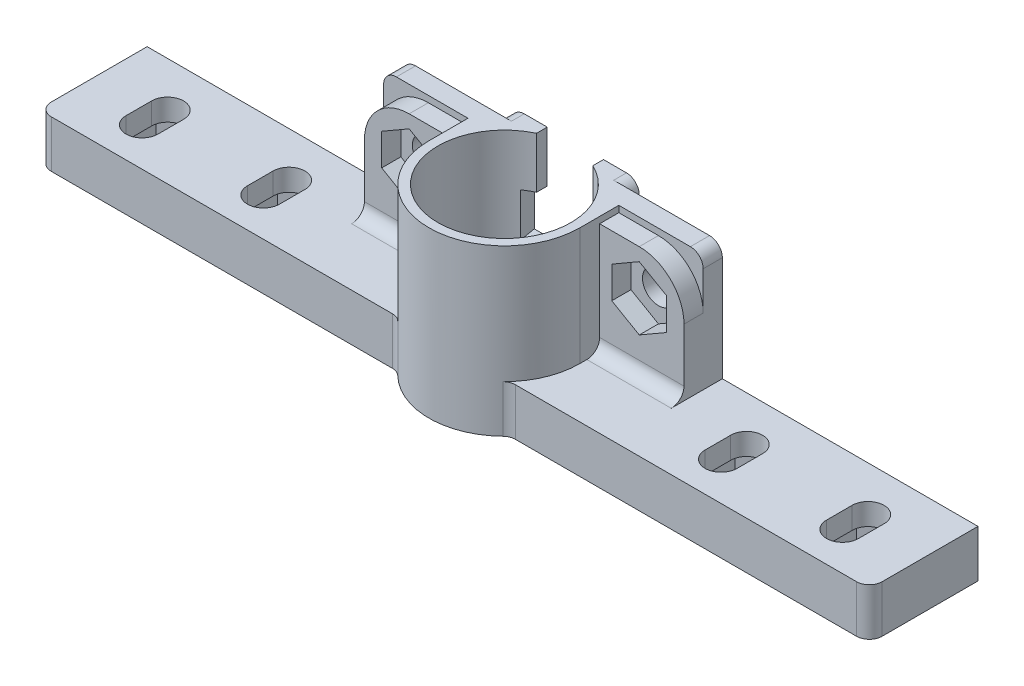
from build123d import *

# Parameters (mm, degrees)
SKETCH1_R                         = 5.2
BASE_SHAPE_DEPTH                  = 11.4
BOTTOM_EXTRUDE_DEPTH              = 1.5
PIN_CUT_REACH                     = 19.917
SKETCH3_R                         = 3
M2_SCREW_HOLES_REACH              = 21.885
SKETCH5_R                         = 1.25
EXTRA_THREAD_EXTRUDES_DEPTH       = 1.5
SKETCH7_R                         = 4.05
INNER_BEARING_FREE_CUT_DEPTH      = 0.5
BUMPER_CUT_DEPTH                  = 1.7
MILLED_HOLE_FILLETS_R             = 1
BUMPER_BODY_TOP_CUT_REACH         = 22.428
BUMPER_BODY_TOP_CUT_END_RADIUS    = 5.2
SKETCH9_W                         = 4.4
SKETCH9_H                         = 4
BUMPER_SWITCH_MOUNT_EXTRUDE_DEPTH = 3.7
BUMPER_SWITCH_MOUNT_FILLETS_R     = 1
BUMPER_SWITCH_NUT_CUTS_DEPTH      = 2


with BuildPart() as part:
    # Sketch1 → Base shape (new body)
    with BuildSketch(Plane(origin=(0, 0, 0), x_dir=(1, 0, 0), z_dir=(0, 1, 0))):
        with BuildLine():
            ThreePointArc((-5.9, 0), (0, -5.9), (5.9, 0))
            Line((5.9, 0), (5.9, 3.05))
            Line((5.9, 3.05), (12.5, 3.05))
            Line((12.5, 3.05), (12.5, 4.55))
            Line((12.5, 4.55), (5, 4.55))
            Line((5, 4.55), (5, 5.55))
            Line((5, 5.55), (-5, 5.55))
            Line((-5, 5.55), (-5, 4.55))
            Line((-5, 4.55), (-12.5, 4.55))
            Line((-12.5, 4.55), (-12.5, 3.05))
            Line((-12.5, 3.05), (-5.9, 3.05))
            Line((-5.9, 3.05), (-5.9, 0))
        make_face()
        with Locations(Location((0, 0, 0), (0, 0, 270))):
            Circle(SKETCH1_R, mode=Mode.SUBTRACT)
    extrude(amount=BASE_SHAPE_DEPTH)

    # Sketch2 → Bottom extrude (add)
    with BuildSketch(Plane.XZ):
        with BuildLine():
            Line((-5.9, -3.05), (-12.5, -3.05))
            Line((-12.5, -3.05), (-12.5, -4.55))
            Line((-12.5, -4.55), (-5, -4.55))
            Line((-5, -4.55), (-5, -5.55))
            Line((-5, -5.55), (5, -5.55))
            Line((5, -5.55), (5, -4.55))
            Line((5, -4.55), (12.5, -4.55))
            Line((12.5, -4.55), (12.5, -3.05))
            Line((12.5, -3.05), (5.9, -3.05))
            Line((5.9, -3.05), (5.9, 0))
            ThreePointArc((5.9, 0), (0, 5.9), (-5.9, 0))
            Line((-5.9, 0), (-5.9, -3.05))
        make_face()
    extrude(amount=BOTTOM_EXTRUDE_DEPTH)

    # Sketch3 → Pin cut (cut, up to next)
    with BuildSketch(Plane(origin=(0, 0, 0), x_dir=(1, 0, 0), z_dir=(0, 1, 0)), mode=Mode.PRIVATE) as pin_cut_sk1:
        with Locations(Location((0, 0, 0), (0, 0, 270))):
            Circle(SKETCH3_R)
    pin_cut_tool1 = extrude(pin_cut_sk1.sketch, amount=-PIN_CUT_REACH, mode=Mode.PRIVATE) & part.part
    add(pin_cut_tool1.solids().sort_by_distance((0, 0, 0))[0], mode=Mode.SUBTRACT)

    # Sketch5 → M2 screw holes (cut, up to next)
    with BuildSketch(Plane(origin=(0, 0, -4.55), x_dir=(-1, 0, 0), z_dir=(0, 0, -1)), mode=Mode.PRIVATE) as m2_screw_holes_sk1:
        with Locations((-9, 7.4)):
            Circle(SKETCH5_R)
    m2_screw_holes_tool1 = extrude(m2_screw_holes_sk1.sketch, amount=-M2_SCREW_HOLES_REACH, mode=Mode.PRIVATE) & part.part
    # Sketch5 → M2 screw holes (cut, up to next)
    with BuildSketch(Plane(origin=(0, 0, -4.55), x_dir=(-1, 0, 0), z_dir=(0, 0, -1)), mode=Mode.PRIVATE) as m2_screw_holes_sk2:
        with Locations((9, 7.4)):
            Circle(SKETCH5_R)
    m2_screw_holes_tool2 = extrude(m2_screw_holes_sk2.sketch, amount=-M2_SCREW_HOLES_REACH, mode=Mode.PRIVATE) & part.part
    add(m2_screw_holes_tool1.solids().sort_by_distance((9, 7.4, -4.55))[0], mode=Mode.SUBTRACT)
    add(m2_screw_holes_tool2.solids().sort_by_distance((-9, 7.4, -4.55))[0], mode=Mode.SUBTRACT)

    # Sketch6 → Extra thread extrudes (add)
    with BuildSketch(Plane.XY.offset(-3.05)):
        with BuildLine():
            Line((-5.9, 5.775192319), (-5.9, 9.024807681))
            ThreePointArc((-5.9, 9.024807681), (-7.18848501, 10.394730946), (-9, 10.9))
            ThreePointArc((-9, 10.9), (-11.474873734, 9.874873734), (-12.5, 7.4))
            ThreePointArc((-12.5, 7.4), (-9.836660027, 4.001470906), (-5.9, 5.775192319))
        make_face()
        Polygon((-11.15, 8.641303079), (-9, 9.882606158), (-6.85, 8.641303079), (-6.85, 6.158696921), (-9, 4.917393842), (-11.15, 6.158696921), align=None, mode=Mode.SUBTRACT)
        with BuildLine():
            Line((-5.9, -1.5), (-5.9, 5.775192319))
            ThreePointArc((-5.9, 5.775192319), (-9.836660027, 4.001470906), (-12.5, 7.4))
            Line((-12.5, 7.4), (-12.5, -1.5))
            Line((-12.5, -1.5), (-5.9, -1.5))
        make_face()
        with BuildLine():
            ThreePointArc((5.9, 5.775192319), (9.836660027, 4.001470906), (12.5, 7.4))
            ThreePointArc((12.5, 7.4), (11.474873734, 9.874873734), (9, 10.9))
            ThreePointArc((9, 10.9), (7.18848501, 10.394730946), (5.9, 9.024807681))
            Line((5.9, 9.024807681), (5.9, 5.775192319))
        make_face()
        Polygon((6.85, 6.158696921), (6.85, 8.641303079), (9, 9.882606158), (11.15, 8.641303079), (11.15, 6.158696921), (9, 4.917393842), align=None, mode=Mode.SUBTRACT)
        with BuildLine():
            Line((5.9, -1.5), (12.5, -1.5))
            Line((12.5, -1.5), (12.5, 7.4))
            ThreePointArc((12.5, 7.4), (9.836660027, 4.001470906), (5.9, 5.775192319))
            Line((5.9, 5.775192319), (5.9, -1.5))
        make_face()
        with BuildLine():
            ThreePointArc((5.9, 9.024807681), (7.18848501, 10.394730946), (9, 10.9))
            Line((9, 10.9), (5.9, 10.9))
            Line((5.9, 10.9), (5.9, 9.024807681))
        make_face()
        with BuildLine():
            Line((-5.9, 9.024807681), (-5.9, 10.9))
            Line((-5.9, 10.9), (-9, 10.9))
            ThreePointArc((-9, 10.9), (-7.18848501, 10.394730946), (-5.9, 9.024807681))
        make_face()
    extrude(amount=EXTRA_THREAD_EXTRUDES_DEPTH)

    # Sketch7 → Inner bearing free cut (cut)
    with BuildSketch(Plane(origin=(0, 0, 0), x_dir=(1, 0, 0), z_dir=(0, 1, 0))):
        with Locations(Location((0, 0, 0), (0, 0, 270))):
            Circle(SKETCH7_R)
    extrude(amount=-INNER_BEARING_FREE_CUT_DEPTH, mode=Mode.SUBTRACT)

    # Sketch8 → Bumper cut (cut, symmetric)
    with BuildSketch(Plane(origin=(0, 5.7, 0), x_dir=(1, 0, 0), z_dir=(0, 1, 0))):
        with BuildLine():
            Line((-3.212553289, 5.55), (-2.166577057, -0.382025991))
            ThreePointArc((-2.166577057, -0.382025991), (-1.685297775, 1.414132741), (0, 2.2))
            Line((0, 2.2), (0, 5.55))
            Line((0, 5.55), (-3.212553289, 5.55))
        make_face()
        with BuildLine():
            Line((0, 5.55), (0, 2.2))
            ThreePointArc((0, 2.2), (1.555634919, 1.555634919), (2.2, 0))
            ThreePointArc((2.2, 0), (2.191628336, -0.191742634), (2.166577057, -0.382025991))
            Line((2.166577057, -0.382025991), (3.212553289, 5.55))
            Line((3.212553289, 5.55), (0, 5.55))
        make_face()
        with BuildLine():
            ThreePointArc((0, 2.2), (-1.685297775, 1.414132741), (-2.166577057, -0.382025991))
            ThreePointArc((-2.166577057, -0.382025991), (-1.414132741, -1.685297775), (0, -2.2))
            Line((0, -2.2), (0, 2.2))
        make_face()
        with BuildLine():
            ThreePointArc((2.2, 0), (1.555634919, 1.555634919), (0, 2.2))
            Line((0, 2.2), (0, -2.2))
            ThreePointArc((0, -2.2), (1.414132741, -1.685297775), (2.166577057, -0.382025991))
            ThreePointArc((2.166577057, -0.382025991), (2.191628336, -0.191742634), (2.2, 0))
        make_face()
    extrude(amount=BUMPER_CUT_DEPTH, both=True, mode=Mode.SUBTRACT)

    # Milled hole fillets
    milled_hole_fillets_edges = [part.edges().sort_by_distance(p)[0] for p in [
        (12.5, 11.4, -3.8),
        (5, 11.4, -5.05),
        (-5, 11.4, -5.05),
        (-12.5, 11.4, -3.8),
        (-5, -1.5, -5.05),
        (5, -1.5, -5.05),
    ]]
    fillet(milled_hole_fillets_edges, radius=MILLED_HOLE_FILLETS_R)

    # Bumper body top cut: up to this cylinder (the profile starts outside it)
    bumper_body_top_cut_end = Plane(origin=(0, 9.4, 0), z_dir=(0, -1, 0)) * Cylinder(BUMPER_BODY_TOP_CUT_END_RADIUS, 56.256, mode=Mode.PRIVATE)
    # Sketch9 → Bumper body top cut (cut, up to the surface)
    with BuildSketch(Plane(origin=(0, 0, -5.55), x_dir=(-1, 0, 0), z_dir=(0, 0, -1)), mode=Mode.PRIVATE) as bumper_body_top_cut_sk1:
        with Locations((0, 9.4)):
            Rectangle(SKETCH9_W, SKETCH9_H)
    bumper_body_top_cut_tool1 = extrude(bumper_body_top_cut_sk1.sketch, amount=-BUMPER_BODY_TOP_CUT_REACH, mode=Mode.PRIVATE) - bumper_body_top_cut_end
    add(bumper_body_top_cut_tool1.solids().sort_by_distance((0, 9.4, -5.55))[0], mode=Mode.SUBTRACT)

    # Sketch10 → Bumper switch mount extrude (add)
    with BuildSketch(Plane.XZ.offset(1.5)):
        with BuildLine():
            Line((-4.382636193, 3.95), (-32.5, 3.95))
            Line((-32.5, 3.95), (-32.5, -4.55))
            Line((-32.5, -4.55), (-12.5, -4.55))
            Line((-12.5, -4.55), (-12.5, -1.55))
            Line((-12.5, -1.55), (-5.9, -1.55))
            Line((-5.9, -1.55), (-5.9, 0))
            ThreePointArc((-5.9, 0), (-5.507610804, 2.115708683), (-4.382636193, 3.95))
        make_face()
        with BuildLine():
            Line((-19.15, -1.05), (-19.15, 0.95))
            ThreePointArc((-19.15, 0.95), (-17.9, 2.2), (-16.65, 0.95))
            Line((-16.65, 0.95), (-16.65, -1.05))
            ThreePointArc((-16.65, -1.05), (-17.9, -2.3), (-19.15, -1.05))
        make_face(mode=Mode.SUBTRACT)
        with BuildLine():
            Line((-26.15, 0.95), (-26.15, -1.05))
            ThreePointArc((-26.15, -1.05), (-27.4, -2.3), (-28.65, -1.05))
            Line((-28.65, -1.05), (-28.65, 0.95))
            ThreePointArc((-28.65, 0.95), (-27.4, 2.2), (-26.15, 0.95))
        make_face(mode=Mode.SUBTRACT)
        with BuildLine():
            Line((32.5, 3.95), (4.382636193, 3.95))
            ThreePointArc((4.382636193, 3.95), (5.507610804, 2.115708683), (5.9, 0))
            Line((5.9, 0), (5.9, -1.55))
            Line((5.9, -1.55), (12.5, -1.55))
            Line((12.5, -1.55), (12.5, -4.55))
            Line((12.5, -4.55), (32.5, -4.55))
            Line((32.5, -4.55), (32.5, 3.95))
        make_face()
        with BuildLine():
            Line((19.15, 0.95), (19.15, -1.05))
            ThreePointArc((19.15, -1.05), (17.9, -2.3), (16.65, -1.05))
            Line((16.65, -1.05), (16.65, 0.95))
            ThreePointArc((16.65, 0.95), (17.9, 2.2), (19.15, 0.95))
        make_face(mode=Mode.SUBTRACT)
        with BuildLine():
            ThreePointArc((28.65, -1.05), (27.4, -2.3), (26.15, -1.05))
            Line((26.15, -1.05), (26.15, 0.95))
            ThreePointArc((26.15, 0.95), (27.4, 2.2), (28.65, 0.95))
            Line((28.65, 0.95), (28.65, -1.05))
        make_face(mode=Mode.SUBTRACT)
    extrude(amount=-BUMPER_SWITCH_MOUNT_EXTRUDE_DEPTH)

    # Bumper switch mount fillets
    bumper_switch_mount_fillets_edges = [part.edges().sort_by_distance(p)[0] for p in [
        (-32.5, 0.35, 3.95),
        (-4.382636193, 0.35, 3.95),
        (-9.2, 2.2, -1.55),
        (4.382636193, 0.35, 3.95),
        (32.5, 0.35, 3.95),
        (9.2, 2.2, -1.55),
    ]]
    fillet(bumper_switch_mount_fillets_edges, radius=BUMPER_SWITCH_MOUNT_FILLETS_R)

    # Sketch12 → Bumper switch nut cuts (cut)
    with BuildSketch(Plane.XZ.offset(1.5)):
        Polygon((-25.25, 2.191303079), (-27.4, 3.432606158), (-29.55, 2.191303079), (-29.55, -2.291303079), (-27.4, -3.532606158), (-25.25, -2.291303079), align=None)
        with BuildLine():
            Line((-26.15, 0.95), (-26.15, -1.05))
            ThreePointArc((-26.15, -1.05), (-27.4, -2.3), (-28.65, -1.05))
            Line((-28.65, -1.05), (-28.65, 0.95))
            ThreePointArc((-28.65, 0.95), (-27.4, 2.2), (-26.15, 0.95))
        make_face(mode=Mode.SUBTRACT)
        Polygon((-20.05, -2.291303079), (-17.9, -3.532606158), (-15.75, -2.291303079), (-15.75, 2.191303079), (-17.9, 3.432606158), (-20.05, 2.191303079), align=None)
        with BuildLine():
            Line((-19.15, -1.05), (-19.15, 0.95))
            ThreePointArc((-19.15, 0.95), (-17.9, 2.2), (-16.65, 0.95))
            Line((-16.65, 0.95), (-16.65, -1.05))
            ThreePointArc((-16.65, -1.05), (-17.9, -2.3), (-19.15, -1.05))
        make_face(mode=Mode.SUBTRACT)
        Polygon((15.75, -2.291303079), (17.9, -3.532606158), (20.05, -2.291303079), (20.05, 2.191303079), (17.9, 3.432606158), (15.75, 2.191303079), align=None)
        with BuildLine():
            ThreePointArc((16.65, 0.95), (17.9, 2.2), (19.15, 0.95))
            Line((19.15, 0.95), (19.15, -1.05))
            ThreePointArc((19.15, -1.05), (17.9, -2.3), (16.65, -1.05))
            Line((16.65, -1.05), (16.65, 0.95))
        make_face(mode=Mode.SUBTRACT)
        Polygon((27.4, -3.532606158), (29.55, -2.291303079), (29.55, 2.191303079), (27.4, 3.432606158), (25.25, 2.191303079), (25.25, -2.291303079), align=None)
        with BuildLine():
            ThreePointArc((28.65, -1.05), (27.4, -2.3), (26.15, -1.05))
            Line((26.15, -1.05), (26.15, 0.95))
            ThreePointArc((26.15, 0.95), (27.4, 2.2), (28.65, 0.95))
            Line((28.65, 0.95), (28.65, -1.05))
        make_face(mode=Mode.SUBTRACT)
    extrude(amount=-BUMPER_SWITCH_NUT_CUTS_DEPTH, mode=Mode.SUBTRACT)


solid = part.part
